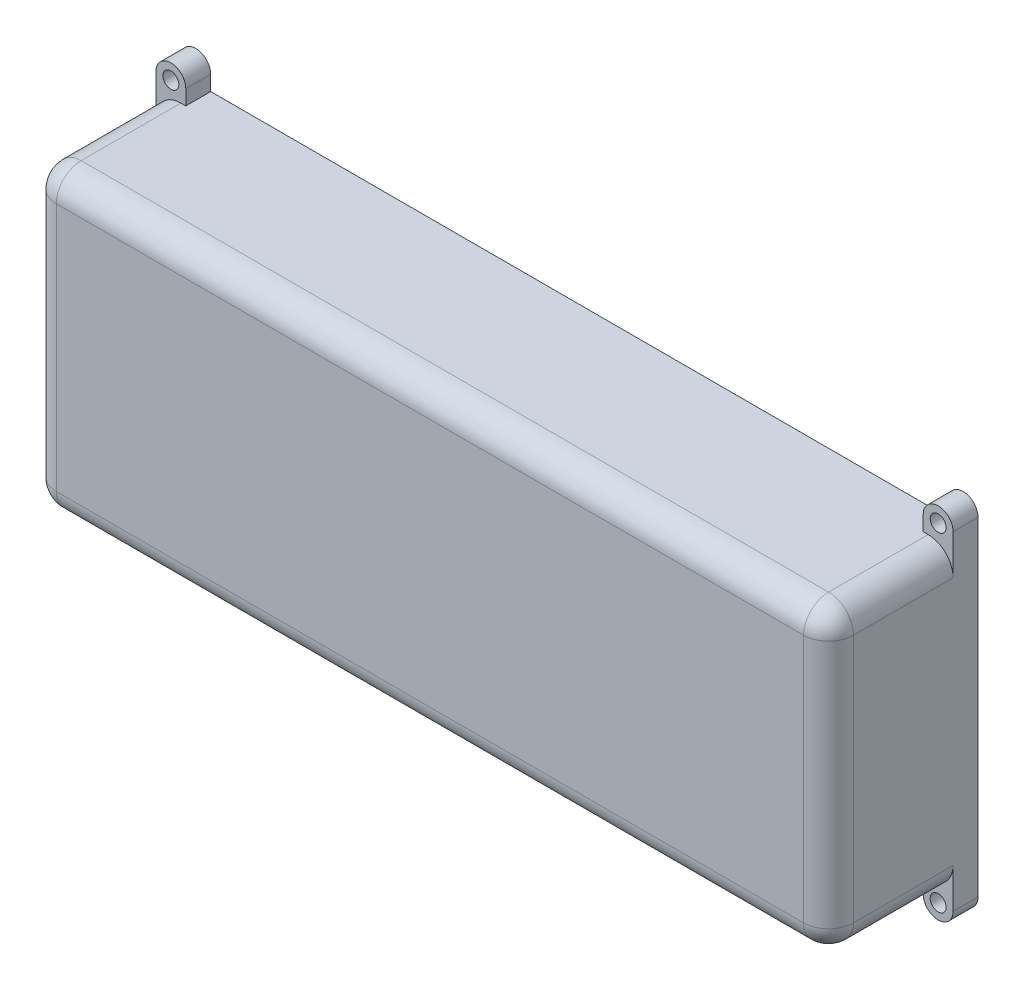
from build123d import *

# Parameters (mm, degrees)
SKETCH1_W                 = 5
SKETCH1_H                 = 50
SKETCH1_H_2               = 60
SKETCH1_W_2               = 2
SKETCH1_H_3               = 10
BOSS_EXTRUDE1_DEPTH       = 25
SKETCH2_W                 = 160
SKETCH2_H                 = 60
BOSS_EXTRUDE2_DEPTH       = 5
SKETCH5_R                 = 3
SKETCH5_R_2               = 1.6
BOSS_EXTRUDE3_DEPTH       = 5
MIRROR2_COPY_1_SKETCH_R   = 3
MIRROR2_COPY_1_SKETCH_R_2 = 1.6
MIRROR2_COPY_1_DEPTH      = 5
FILLET1_R                 = 5


with BuildPart() as part:
    # Sketch1 → Boss-Extrude1 (new body)
    with BuildSketch(Plane.XY):
        with Locations((77.5, 0)):
            Rectangle(SKETCH1_W, SKETCH1_H)
        Polygon((-75, -25), (-75, -30), (80, -30), (80, -25), (75, -25), (65, -25), (63, -25), align=None)
        with Locations((-77.5, 0)):
            Rectangle(SKETCH1_W, SKETCH1_H_2)
        Polygon((80, 30), (-75, 30), (-75, 25), (63, 25), (65, 25), (75, 25), (80, 25), align=None)
        with Locations((64, -20)):
            Rectangle(SKETCH1_W_2, SKETCH1_H_3)
        with Locations((64, 20)):
            Rectangle(SKETCH1_W_2, SKETCH1_H_3)
    extrude(amount=BOSS_EXTRUDE1_DEPTH)

    # Sketch2 → Boss-Extrude2 (add)
    with BuildSketch(Plane.XY.offset(25)):
        Rectangle(SKETCH2_W, SKETCH2_H)
    extrude(amount=BOSS_EXTRUDE2_DEPTH)

    # Sketch5 → Boss-Extrude3 (add)
    with BuildSketch(Plane(origin=(0, 0, 0), x_dir=(-1, 0, 0), z_dir=(0, 0, -1))):
        with Locations((77, -33)):
            Circle(SKETCH5_R)
        with Locations((77, -33)):
            Circle(SKETCH5_R_2, mode=Mode.SUBTRACT)
        with BuildLine():
            ThreePointArc((77, -30), (79.121320344, -30.878679656), (80, -33))
            Line((80, -33), (80, -30))
            Line((80, -30), (77, -30))
        make_face()
        with BuildLine():
            Line((74, -30), (74, -33))
            ThreePointArc((74, -33), (74.878679656, -30.878679656), (77, -30))
            Line((77, -30), (74, -30))
        make_face()
    boss_extrude3 = extrude(amount=-BOSS_EXTRUDE3_DEPTH)

    # Mirror1: Boss-Extrude3 across plane
    add(boss_extrude3.mirror(Plane(origin=(0, 0, 0), x_dir=(0, 0, 1), z_dir=(1, 0, 0))))

    # Mirror2: Boss-Extrude3 across plane
    add(boss_extrude3.mirror(Plane.ZX))

    # Mirror2 copy 1 sketch → Mirror2 copy 1 (add)
    with BuildSketch(Plane(origin=(0, 0, 0), x_dir=(1, 0, 0), z_dir=(0, 0, -1))):
        with Locations((77, -33)):
            Circle(MIRROR2_COPY_1_SKETCH_R)
        with Locations((77, -33)):
            Circle(MIRROR2_COPY_1_SKETCH_R_2, mode=Mode.SUBTRACT)
        with BuildLine():
            ThreePointArc((77, -30), (79.121320344, -30.878679656), (80, -33))
            Line((80, -33), (80, -30))
            Line((80, -30), (77, -30))
        make_face()
        with BuildLine():
            Line((74, -30), (74, -33))
            ThreePointArc((74, -33), (74.878679656, -30.878679656), (77, -30))
            Line((77, -30), (74, -30))
        make_face()
    extrude(amount=-MIRROR2_COPY_1_DEPTH)

    # Fillet1
    fillet1_edges = [part.edges().sort_by_distance(p)[0] for p in [
        (-80, 30, 17.5),
        (80, 30, 17.5),
        (80, -30, 17.5),
        (-80, -30, 17.5),
        (0, 30, 30),
        (-80, 0, 30),
        (0, -30, 30),
        (80, 0, 30),
    ]]
    fillet(fillet1_edges, radius=FILLET1_R)


solid = part.part
